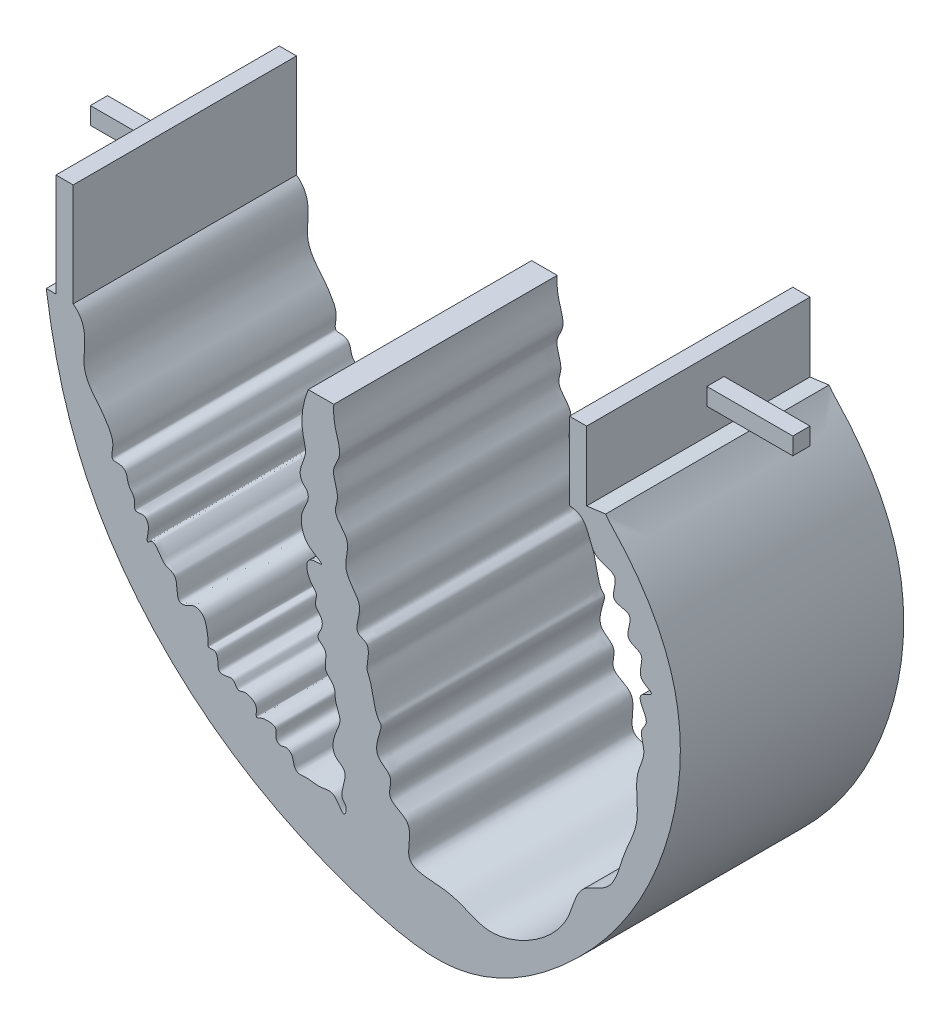
from build123d import *

# Parameters (mm, degrees)
BOSS_EXTRUDE1_DEPTH = 33.02
SKETCH2_W           = 2.54
SKETCH2_H           = 2.54
BOSS_EXTRUDE2_DEPTH = 12.7
SKETCH3_W           = 2.54
SKETCH3_H           = 2.54
BOSS_EXTRUDE3_DEPTH = 12.7


with BuildPart() as part:
    # Sketch1 → Boss-Extrude1 (new body)
    with BuildSketch(Plane.XY):
        with BuildLine():
            Line((156.428372023, 303.800778291), (157.863136348, 303.800778291))
            Line((157.863136348, 303.800778291), (157.863136348, 319.040778291))
            Line((157.863136348, 319.040778291), (160.403136348, 319.040778291))
            Line((160.403136348, 319.040778291), (160.403136348, 303.800778291))
            add(Edge.make_bspline(
                [(160.403136348, 303.800778291), (162.294103725, 302.378890696), (162.160879846, 299.73791997), (161.914782074, 296.395672853), (162.817704167, 294.287183203), (164.415839534, 292.572183955), (165.723740531, 290.605551934), (166.541103744, 288.833429196), (165.776439451, 286.514105378), (167.459676955, 286.857608577), (168.441373384, 286.036193561), (168.385675137, 284.529252049), (169.753109248, 283.618390445), (169.221113918, 281.496181727), (170.96359801, 282.25752058), (171.596943914, 281.055521657), (171.509265666, 280.234054257), (171.174929696, 278.417258681), (172.123862672, 279.506925803), (172.964237505, 278.594431051), (173.398484414, 277.811842346), (174.202477578, 277.000272495), (175.453450059, 276.803752533), (175.824686289, 275.235244262), (175.740374736, 273.311268353), (177.316306141, 273.520688136), (178.183587724, 274.304041623), (179.810596493, 273.697512264), (180.158855624, 272.01419868), (180.388526886, 270.909188533), (180.26726562, 269.624772341), (181.357001497, 270.116738343), (181.726676595, 269.287236984), (181.820665539, 268.556897223), (181.811421683, 267.263398132), (183.095191598, 267.487534991), (184.230649198, 267.713235204), (184.64181633, 266.261715194), (185.659446478, 266.852595649), (186.649632797, 266.61611619), (187.793151969, 265.953885019), (187.226872697, 264.137849377), (188.374876326, 264.830102197), (189.156403231, 264.820224676), (190.728014144, 264.741151645), (190.07746036, 263.223005035), (191.045240062, 262.441385832), (191.905912659, 262.942327268), (193.008945519, 262.173215169), (192.901516804, 261.037095079), (193.657819474, 260.255192476), (195.110942606, 260.558990897), (196.771169942, 259.951158822), (199.182731596, 260.89087277), (200.399769785, 257.584690042), (200.938532357, 259.624674297), (199.345500123, 260.901950097), (201.659717079, 263.942178371), (198.375297663, 265.350642625), (198.996810197, 268.124351538), (200.230372523, 270.38509473), (198.963711248, 272.202186532), (199.263216503, 274.319027032), (197.023809703, 275.551898422), (198.369001189, 278.0602628), (196.126890521, 279.120033768), (197.246818775, 280.514392052), (197.295210609, 282.071791348), (195.857044345, 283.050448322), (196.66960976, 284.708807787), (195.046590082, 285.888041608), (194.440854031, 289.063655861), (198.190619939, 288.542233229), (195.171528415, 290.012847888), (194.260939097, 291.581227721), (193.748375737, 294.538939305), (196.008442266, 296.590582739), (194.438940738, 297.714635044)],
                knots=[0, 0, 0, 0, 0.049996005, 0.065888702, 0.085586213, 0.106494439, 0.126329724, 0.145329526, 0.158777193, 0.169850833, 0.176820241, 0.189609232, 0.203968037, 0.21536807, 0.226543746, 0.234051329, 0.244076928, 0.254102528, 0.259848499, 0.267500205, 0.278630427, 0.28537446, 0.295913268, 0.307178135, 0.324487686, 0.330940071, 0.342392975, 0.353020843, 0.368288905, 0.381906755, 0.386446039, 0.394300221, 0.399825603, 0.405923938, 0.415167084, 0.425567015, 0.431874123, 0.443149812, 0.44976232, 0.456278641, 0.469389775, 0.478958197, 0.484911178, 0.493692474, 0.502959189, 0.515400041, 0.52219998, 0.52875964, 0.537962254, 0.549765551, 0.555957527, 0.562483418, 0.585296455, 0.601031502, 0.62043878, 0.629585476, 0.635431428, 0.669716292, 0.683063091, 0.71115835, 0.727063046, 0.746976021, 0.761152301, 0.777279595, 0.79970392, 0.811466829, 0.824175792, 0.835068284, 0.849297003, 0.860204494, 0.872606633, 0.897258064, 0.910613563, 0.929465363, 0.942874958, 0.963602921, 1, 1, 1, 1], degree=3))
            add(Edge.make_bspline(
                [(194.438940738, 297.714635044), (193.239475577, 299.228279632), (195.273066719, 301.172844838), (193.838115627, 305.335217988), (194.338223402, 308.213188839), (195.150530917, 310.217861142)],
                knots=[0, 0, 0, 0, 0.340368566, 0.485096312, 1, 1, 1, 1], degree=3))
            Line((195.150530917, 310.217861142), (198.930367555, 310.217861142))
            add(Edge.make_bspline(
                [(233.754784279, 314.683303055), (236.948074465, 314.481726499), (235.934813662, 309.485950017), (241.631424233, 309.648350136), (239.263257233, 305.309895583), (243.891726253, 305.694828868), (241.323898684, 301.654384787), (245.549138654, 301.18453362), (243.135720739, 297.782942112), (246.899728073, 296.606510149), (242.779101557, 295.706262014), (245.934861415, 293.006908949), (243.943396072, 291.086766858), (245.306869031, 288.554785356), (243.010604532, 284.760227875), (244.583076617, 279.366500247), (241.43026217, 274.073380998), (240.489262334, 268.299289429), (234.893068517, 267.000851575), (234.173198006, 262.627976851), (231.749532524, 258.900244122), (227.837860056, 255.635271223), (221.367174921, 253.301749449), (216.427223678, 256.918520909), (208.454768062, 255.959767182), (211.273727911, 262.601783314), (206.360432744, 263.510981124), (208.029706699, 267.036431497), (204.138636871, 268.31237495), (206.616335693, 273.097838067), (205.249340756, 272.837518316), (204.247892346, 278.574922601), (203.517097239, 278.060156389), (204.537572962, 282.673976641), (201.530122152, 282.149017966), (203.07155312, 285.882564362), (201.960564102, 287.986829266), (199.913257842, 290.059992358), (201.855033301, 293.930110001), (198.617045745, 296.082230584), (199.97814261, 299.037257515), (198.225152061, 301.528423708), (200.297375827, 304.199019126), (199.001219724, 307.09657511), (198.852215803, 309.174015251), (198.930367555, 310.217861142)],
                knots=[0, 0, 0, 0, 0.037446082, 0.059443775, 0.080190023, 0.096299779, 0.118582786, 0.133282306, 0.156258978, 0.168723137, 0.181203037, 0.205033763, 0.213725914, 0.232528559, 0.255370457, 0.302462961, 0.341301096, 0.386327976, 0.4131565, 0.448752757, 0.470339799, 0.508948117, 0.558766661, 0.6000397, 0.642673186, 0.67485127, 0.697745423, 0.715395831, 0.73376175, 0.762664326, 0.781599127, 0.792164345, 0.818097156, 0.837306645, 0.857123457, 0.872663691, 0.87631789, 0.893665446, 0.912488229, 0.929179034, 0.938318126, 0.956848262, 0.966871949, 0.984330749, 1, 1, 1, 1], degree=3))
            Line((233.754784279, 314.683303055), (233.754784279, 326.113303055))
            Line((233.754784279, 326.113303055), (236.294784279, 326.113303055))
            Line((236.294784279, 326.113303055), (236.294784279, 315.886591298))
            Line((236.294784279, 315.886591298), (239.104934874, 316.264879949))
            add(Edge.make_bspline(
                [(156.428372023, 303.800778291), (157.414889581, 296.727548826), (161.288841581, 280.508514514), (178.216271, 259.818321197), (198.545279867, 249.618361545), (218.657994732, 245.023183274), (234.970537313, 255.628943237), (248.357422291, 273.771705936), (252.56195564, 297.430016755), (244.028678127, 311.069677221), (239.480585862, 315.706633531), (239.104934874, 316.264879949)],
                knots=[0.117891425, 0.117891425, 0.117891425, 0.117891425, 0.184833858, 0.273021776, 0.359649237, 0.397816634, 0.461195161, 0.526426676, 0.612455038, 0.666069007, 0.672633998, 0.672633998, 0.672633998, 0.672633998], degree=3))
        make_face()
    extrude(amount=BOSS_EXTRUDE1_DEPTH)

    # Sketch2 → Boss-Extrude2 (add)
    with BuildSketch(Plane.ZY.offset(-157.863136348)):
        with Locations((13.97, 311.420778291)):
            Rectangle(SKETCH2_W, SKETCH2_H)
    extrude(amount=BOSS_EXTRUDE2_DEPTH)

    # Sketch3 → Boss-Extrude3 (add)
    with BuildSketch(Plane(origin=(236.294784279, 0, 0), x_dir=(0, 0, -1), z_dir=(1, 0, 0))):
        with Locations((-13.97, 321.033303055)):
            Rectangle(SKETCH3_W, SKETCH3_H)
    extrude(amount=BOSS_EXTRUDE3_DEPTH)


solid = part.part
